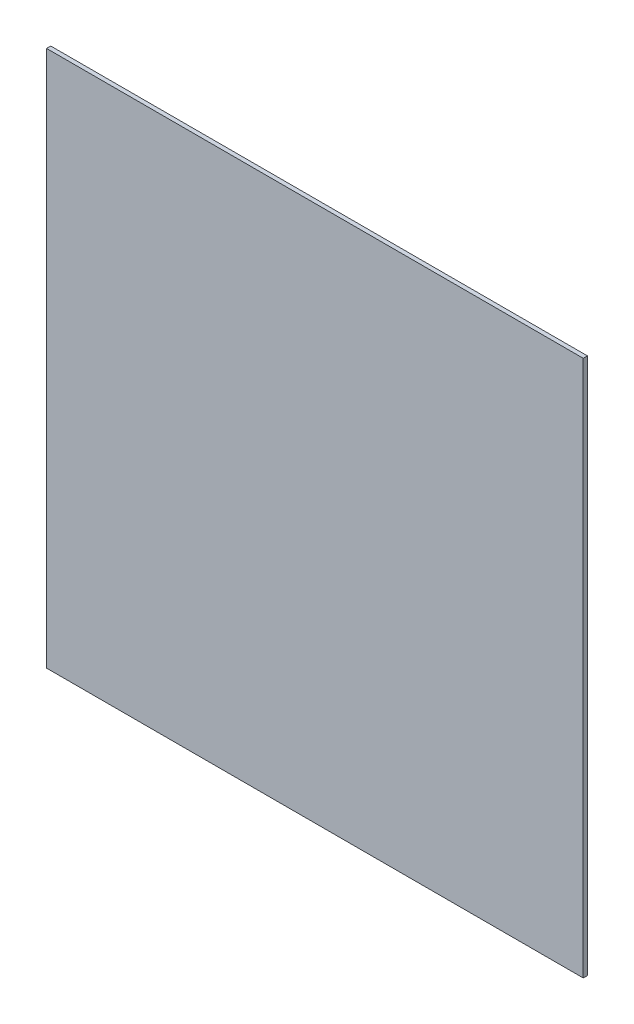
from build123d import *

# Parameters (mm, degrees)
SKETCH1_W           = 1219.2
SKETCH1_H           = 1219.2
BOSS_EXTRUDE1_DEPTH = 9.525


with BuildPart() as part:
    # Sketch1 → Boss-Extrude1 (new body)
    with BuildSketch(Plane.XY):
        with Locations((609.6, 609.6)):
            Rectangle(SKETCH1_W, SKETCH1_H)
    extrude(amount=BOSS_EXTRUDE1_DEPTH)


solid = part.part
